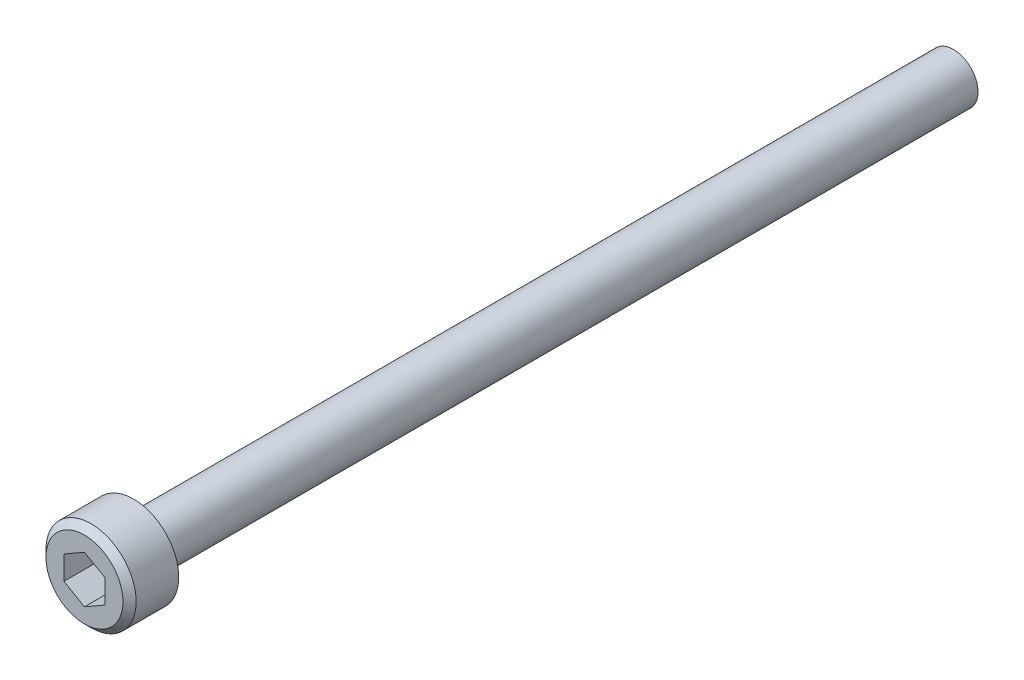
from build123d import *

# Parameters (mm, degrees)
SKETCH_1_W          = 2.75
SKETCH_1_H          = 3
SKETCH_2_R          = 1.5
EXTRUDE_1_DEPTH     = 50
CUT_EXTRUDE_1_DEPTH = 2.5
CHAMFER_1_SIZE      = 0.4
CHAMFER_2_SIZE      = 0.1


with BuildPart() as part:
    # 草图1 → 旋转1 (revolve)
    with BuildSketch(Plane(origin=(0, 0, 0), x_dir=(1, 0, 0), z_dir=(0, 1, 0))):
        with Locations((1.375, -1.5)):
            Rectangle(SKETCH_1_W, SKETCH_1_H)
    revolve(axis=Axis((0, 0, 0), (0, 0, 1)))

    # 草图2 → 凸台-拉伸1 (add)
    with BuildSketch(Plane(origin=(0, 0, 0), x_dir=(-1, 0, 0), z_dir=(0, 0, -1))):
        Circle(SKETCH_2_R)
    extrude(amount=EXTRUDE_1_DEPTH)

    # 草图3 → 切除-拉伸1 (cut)
    with BuildSketch(Plane.XY.offset(3)):
        Polygon((1.248513905, -0.724255729), (1.251480813, 0.719116894), (0.002966908, 1.443372624), (-1.248513905, 0.724255729), (-1.251480813, -0.719116894), (-0.002966908, -1.443372624), align=None)
    extrude(amount=-CUT_EXTRUDE_1_DEPTH, mode=Mode.SUBTRACT)

    # 倒角1
    chamfer_1_edges = [part.edges().sort_by_distance(p)[0] for p in [
        (-2.75, 0, 3),
    ]]
    chamfer(chamfer_1_edges, length=CHAMFER_1_SIZE)

    # 倒角2
    chamfer_2_edges = [part.edges().sort_by_distance(p)[0] for p in [
        (1.5, 0, 0),
    ]]
    chamfer(chamfer_2_edges, length=CHAMFER_2_SIZE)


solid = part.part
